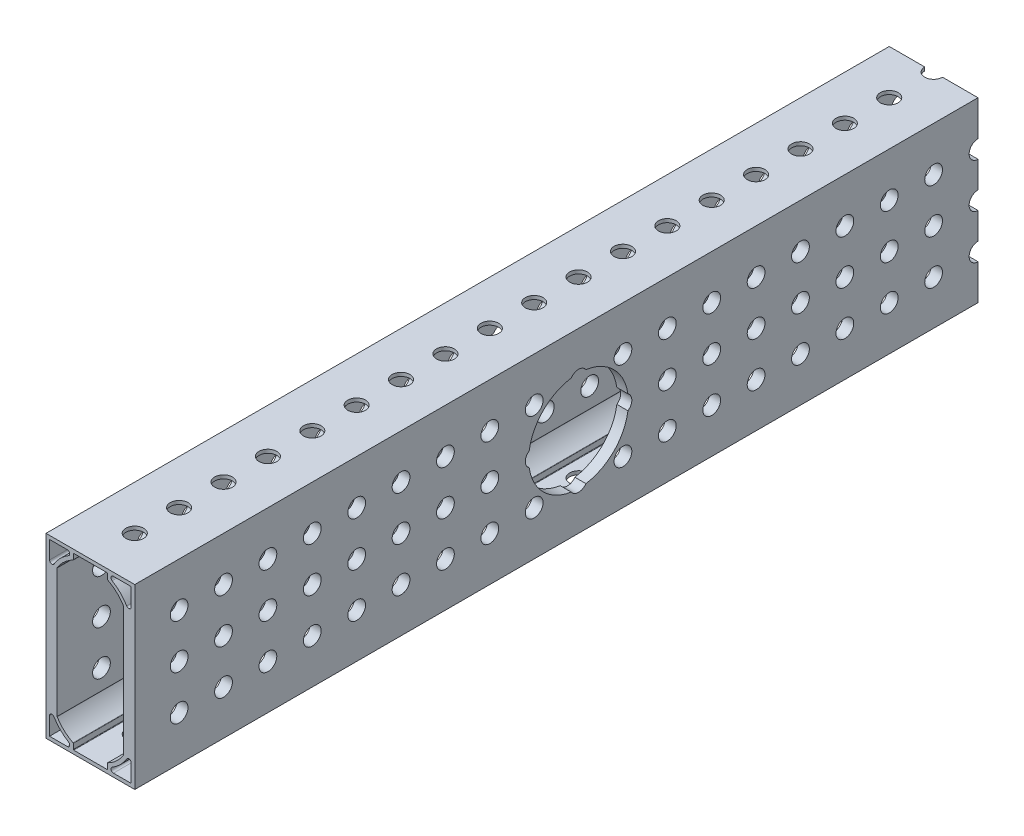
from build123d import *

# Parameters (mm, degrees)
SKETCH1_W                                = 50.8
SKETCH1_H                                = 241.3
BOSS_EXTRUDE1_DEPTH                      = 25.4
CUT_EXTRUDE9_DEPTH                       = 242.3
MIRROR1_AT_THE_SECOND_PLANE_COPY_1_DEPTH = 242.3
CUT_EXTRUDE11_START                      = -26.4
SKETCH17_R                               = 2.54
CUT_EXTRUDE11_DEPTH                      = 27.4
SKETCH18_R                               = 2.54
CUT_EXTRUDE12_DEPTH                      = 51.8
LPATTERN1_COUNT                          = 19
LPATTERN1_PITCH                          = 12.7
LPATTERN2_COUNT                          = 20
LPATTERN2_PITCH                          = 12.7
LPATTERN2_COUNT_DIR2                     = 3
LPATTERN2_PITCH_DIR2                     = 12.7
FILLET1_R                                = 0.127
SKETCH19_R                               = 14.2875
CUT_EXTRUDE13_DEPTH                      = 26.4


with BuildPart() as part:
    # Sketch1 → Boss-Extrude1 (new body)
    with BuildSketch(Plane(origin=(-12.7, 0, 0), x_dir=(0, -1, 0), z_dir=(-1, 0, 0))):
        Rectangle(SKETCH1_W, SKETCH1_H)
    extrude(amount=-BOSS_EXTRUDE1_DEPTH)

    # Sketch10 → Cut-Extrude9 (cut, through all)
    with BuildSketch(Plane.XY.offset(120.65)):
        with BuildLine():
            Line((-11.684, 24.384), (-11.684, 19.297089026))
            ThreePointArc((-11.684, 19.297089026), (-11.177055919, 18.630604499), (-10.39941737, 18.941204261))
            ThreePointArc((-10.39941737, 18.941204261), (-8.576144596, 21.276144596), (-6.241204261, 23.09941737))
            ThreePointArc((-6.241204261, 23.09941737), (-5.930604499, 23.877055919), (-6.597089026, 24.384))
            Line((-6.597089026, 24.384), (-11.684, 24.384))
        make_face()
        with BuildLine():
            Line((0, 24.384), (-4.8895, 24.384))
            Line((-4.8895, 24.384), (-4.8895, 22.679000251))
            ThreePointArc((-4.8895, 22.679000251), (-7.514726072, 20.886363558), (-9.525, 18.42381265))
            Line((-9.525, 18.42381265), (-9.525, 0))
            Line((-9.525, 0), (0, 0))
            Line((0, 0), (0, 24.384))
        make_face()
    cut_extrude9 = extrude(amount=-CUT_EXTRUDE9_DEPTH, mode=Mode.SUBTRACT)

    # Mirror1: Cut-Extrude9 across plane
    add(cut_extrude9.mirror(Plane.ZX), mode=Mode.SUBTRACT)

    # Mirror1 at the second plane: Cut-Extrude9 across plane
    add(cut_extrude9.mirror(Plane(origin=(0, 0, 0), x_dir=(0, 0, 1), z_dir=(1, 0, 0))), mode=Mode.SUBTRACT)

    # Mirror1 at the second plane copy 1 sketc → Mirror1 at the second plane copy 1 (cut, through all)
    with BuildSketch(Plane(origin=(0, 0, 120.65), x_dir=(-1, 0, 0), z_dir=(0, 0, 1))):
        with BuildLine():
            Line((-11.684, 24.384), (-11.684, 19.297089026))
            ThreePointArc((-11.684, 19.297089026), (-11.177055919, 18.630604499), (-10.39941737, 18.941204261))
            ThreePointArc((-10.39941737, 18.941204261), (-8.576144596, 21.276144596), (-6.241204261, 23.09941737))
            ThreePointArc((-6.241204261, 23.09941737), (-5.930604499, 23.877055919), (-6.597089026, 24.384))
            Line((-6.597089026, 24.384), (-11.684, 24.384))
        make_face()
        with BuildLine():
            Line((0, 24.384), (-4.8895, 24.384))
            Line((-4.8895, 24.384), (-4.8895, 22.679000251))
            ThreePointArc((-4.8895, 22.679000251), (-7.514726072, 20.886363558), (-9.525, 18.42381265))
            Line((-9.525, 18.42381265), (-9.525, 0))
            Line((-9.525, 0), (0, 0))
            Line((0, 0), (0, 24.384))
        make_face()
    extrude(amount=-MIRROR1_AT_THE_SECOND_PLANE_COPY_1_DEPTH, mode=Mode.SUBTRACT)

    # Sketch17 → Cut-Extrude11 (cut)
    with BuildSketch(Plane(origin=(12.7, 0, 0), x_dir=(0, 0, -1), z_dir=(1, 0, 0)).offset(CUT_EXTRUDE11_START)):
        with Locations((-107.95, 12.7)):
            Circle(SKETCH17_R)
    cut_extrude11 = extrude(amount=CUT_EXTRUDE11_DEPTH, mode=Mode.SUBTRACT)

    # Sketch18 → Cut-Extrude12 (cut, through all)
    with BuildSketch(Plane(origin=(0, 25.4, 0), x_dir=(1, 0, 0), z_dir=(0, 1, 0))):
        with Locations((0, -107.95)):
            Circle(SKETCH18_R)
    cut_extrude12 = extrude(amount=-CUT_EXTRUDE12_DEPTH, mode=Mode.SUBTRACT)

    # LPattern1: Cut-Extrude12 ×19
    with Locations(*[(0, 0, -i * LPATTERN1_PITCH) for i in range(1, LPATTERN1_COUNT)]):
        add(cut_extrude12, mode=Mode.SUBTRACT)

    # LPattern2: Cut-Extrude11 20 × 3
    with Locations(*[(0, -j * LPATTERN2_PITCH_DIR2, -i * LPATTERN2_PITCH) for i in range(LPATTERN2_COUNT) for j in range(LPATTERN2_COUNT_DIR2) if (i, j) != (0, 0)]):
        add(cut_extrude11, mode=Mode.SUBTRACT)

    # Fillet1
    fillet1_edges = [part.edges().sort_by_distance(p)[0] for p in [
        (-4.8895, -24.384, 0),
        (-4.8895, -22.679000251, 0),
        (-9.525, -18.42381265, 0),
        (4.8895, -22.679000251, 0),
        (4.8895, -24.384, 0),
        (9.525, -18.42381265, 0),
        (-4.8895, 22.679000251, 0),
        (-4.8895, 24.384, 0),
        (-9.525, 18.42381265, 0),
        (4.8895, 24.384, 0),
        (4.8895, 22.679000251, 0),
        (9.525, 18.42381265, 0),
    ]]
    fillet(fillet1_edges, radius=FILLET1_R)

    # Sketch19 → Cut-Extrude13 (cut, through all)
    with BuildSketch(Plane.ZY.offset(12.7)):
        with Locations((-6.35, 0)):
            Circle(SKETCH19_R)
    extrude(amount=-CUT_EXTRUDE13_DEPTH, mode=Mode.SUBTRACT)


solid = part.part
